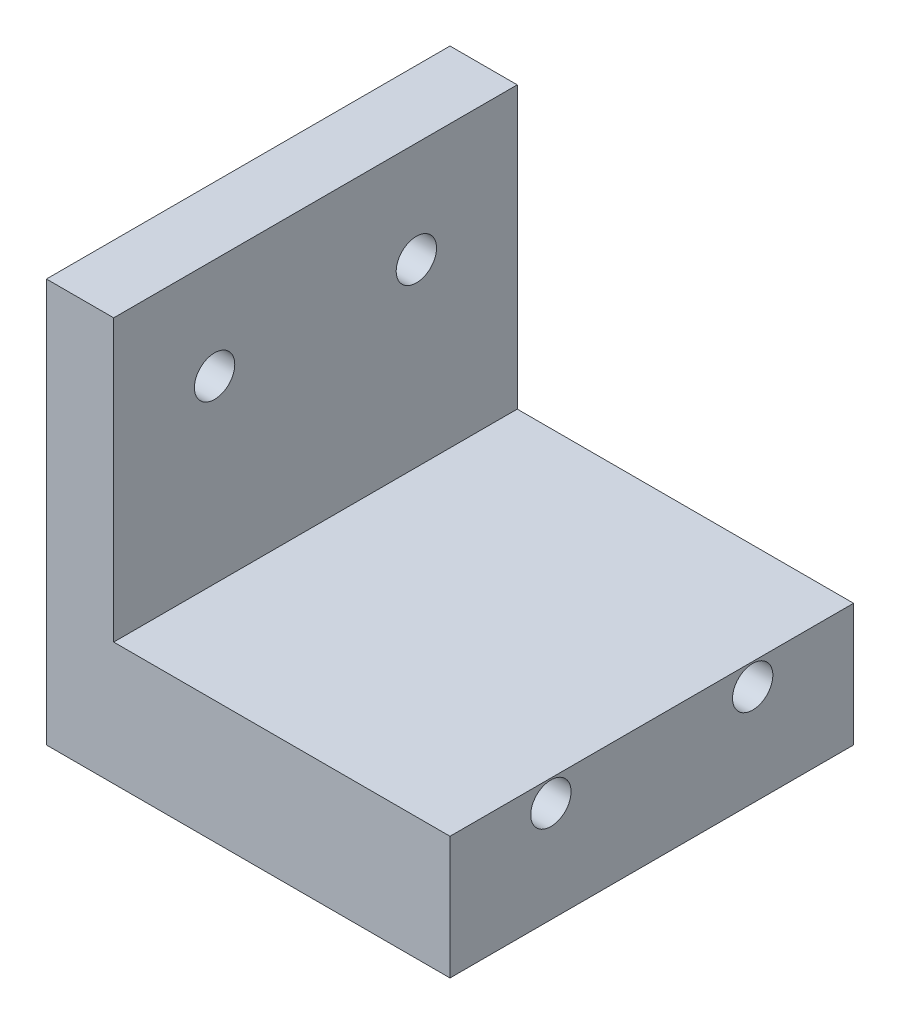
from build123d import *

# Parameters (mm, degrees)
SKETCH1_W            = 60
SKETCH1_H            = 60
BOSS_EXTRUDE1_DEPTH  = 60
SKETCH2_R            = 3
CUT_EXTRUDE1_DEPTH   = 61
LPATTERN1_COUNT      = 2
LPATTERN1_PITCH      = 30
LPATTERN1_COUNT_DIR2 = 2
LPATTERN1_PITCH_DIR2 = 30
CUT_EXTRUDE3_REACH   = 62
SKETCH4_W            = 40
SKETCH4_H            = 41.75
CUT_EXTRUDE5_REACH   = 62
SKETCH6_W            = 10
SKETCH6_H            = 41.75


with BuildPart() as part:
    # Sketch1 → Boss-Extrude1 (new body)
    with BuildSketch(Plane(origin=(0, 0, 0), x_dir=(1, 0, 0), z_dir=(0, 1, 0))):
        Rectangle(SKETCH1_W, SKETCH1_H)
    extrude(amount=BOSS_EXTRUDE1_DEPTH)

    # Sketch2 → Cut-Extrude1 (cut, through all)
    with BuildSketch(Plane(origin=(30, 0, 0), x_dir=(0, 0, -1), z_dir=(1, 0, 0))):
        with Locations((-15, 45)):
            Circle(SKETCH2_R)
    cut_extrude1 = extrude(amount=-CUT_EXTRUDE1_DEPTH, mode=Mode.SUBTRACT)

    # LPattern1: Cut-Extrude1 2 × 2
    with Locations(*[(0, -j * LPATTERN1_PITCH_DIR2, -i * LPATTERN1_PITCH) for i in range(LPATTERN1_COUNT) for j in range(LPATTERN1_COUNT_DIR2) if (i, j) != (0, 0)]):
        add(cut_extrude1, mode=Mode.SUBTRACT)

    # Sketch4 → Cut-Extrude3 (cut, up to next)
    with BuildSketch(Plane(origin=(0, 0, -30), x_dir=(-1, 0, 0), z_dir=(0, 0, -1)), mode=Mode.PRIVATE) as cut_extrude3_sk1:
        with Locations((0, 39.125)):
            Rectangle(SKETCH4_W, SKETCH4_H)
    cut_extrude3_tool1 = extrude(cut_extrude3_sk1.sketch, amount=-CUT_EXTRUDE3_REACH, mode=Mode.PRIVATE) & part.part
    add(cut_extrude3_tool1.solids().sort_by_distance((0, 39.125, -30))[0], mode=Mode.SUBTRACT)

    # Sketch6 → Cut-Extrude5 (cut, up to next)
    with BuildSketch(Plane.XY.offset(30), mode=Mode.PRIVATE) as cut_extrude5_sk1:
        with Locations((25, 39.125)):
            Rectangle(SKETCH6_W, SKETCH6_H)
    cut_extrude5_tool1 = extrude(cut_extrude5_sk1.sketch, amount=-CUT_EXTRUDE5_REACH, mode=Mode.PRIVATE) & part.part
    add(cut_extrude5_tool1.solids().sort_by_distance((25, 39.125, 30))[0], mode=Mode.SUBTRACT)


solid = part.part
